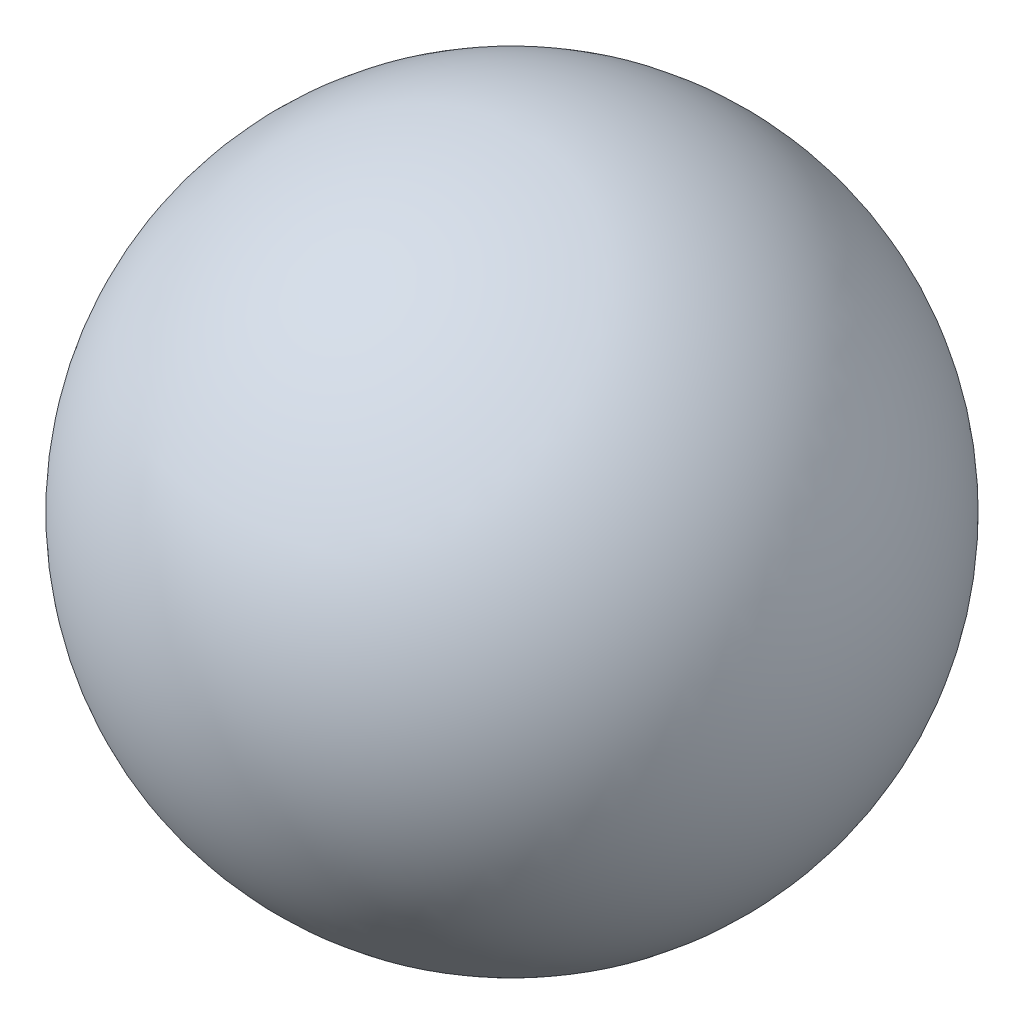
from build123d import *


with BuildPart() as part:
    # Sketch1 → Revolve2 (revolve)
    with BuildSketch(Plane.XY):
        with BuildLine():
            Line((0, -10), (0, 10))
            ThreePointArc((0, 10), (10, 0), (0, -10))
        make_face()
    revolve(axis=Axis((0, -10, 0), (0, 1, 0)))


solid = part.part
